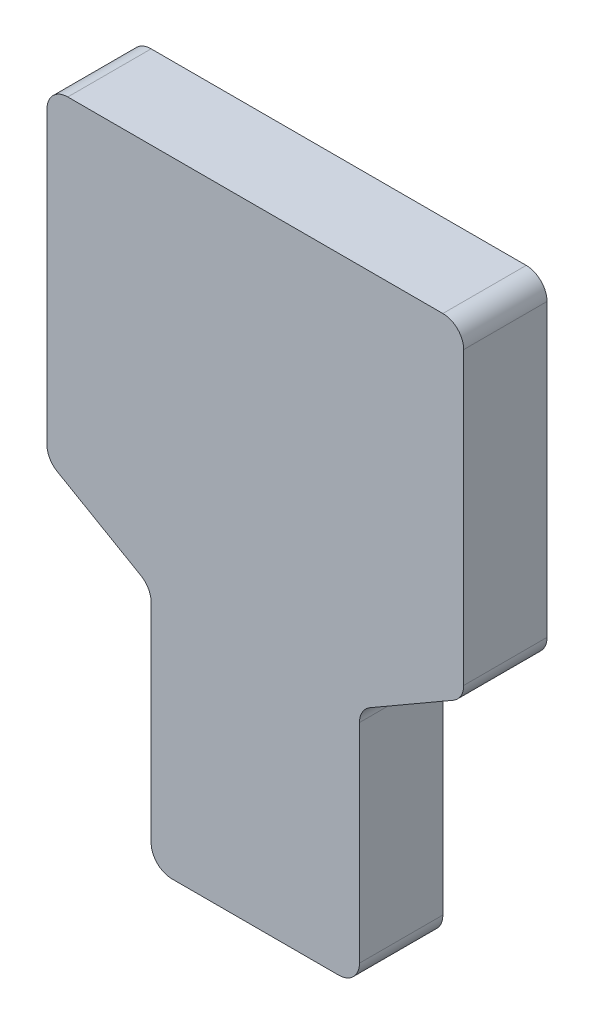
from build123d import *

# Parameters (mm, degrees)
RESSALTO_EXTRUS_O1_DEPTH = 20


with BuildPart() as part:
    # Esboço1 → Ressalto-extrusão1 (new body, symmetric)
    with BuildSketch(Plane.XY):
        with BuildLine():
            Line((-40, 0), (40, 0))
            ThreePointArc((40, 0), (47.071067812, 2.928932188), (50, 10))
            Line((50, 10), (50, 110))
            ThreePointArc((50, 110), (51.339745962, 115), (55, 118.660254038))
            Line((55, 118.660254038), (95, 141.754264805))
            ThreePointArc((95, 141.754264805), (98.660254038, 145.414518843), (100, 150.414518843))
            Line((100, 150.414518843), (100, 290))
            ThreePointArc((100, 290), (97.071067812, 297.071067812), (90, 300))
            Line((90, 300), (-90, 300))
            ThreePointArc((-90, 300), (-97.071067812, 297.071067812), (-100, 290))
            Line((-100, 290), (-100, 150.414518843))
            ThreePointArc((-100, 150.414518843), (-98.660254038, 145.414518843), (-95, 141.754264805))
            Line((-95, 141.754264805), (-55, 118.660254038))
            ThreePointArc((-55, 118.660254038), (-51.339745962, 115), (-50, 110))
            Line((-50, 110), (-50, 10))
            ThreePointArc((-50, 10), (-47.071067812, 2.928932188), (-40, 0))
        make_face()
    extrude(amount=RESSALTO_EXTRUS_O1_DEPTH, both=True)


solid = part.part
